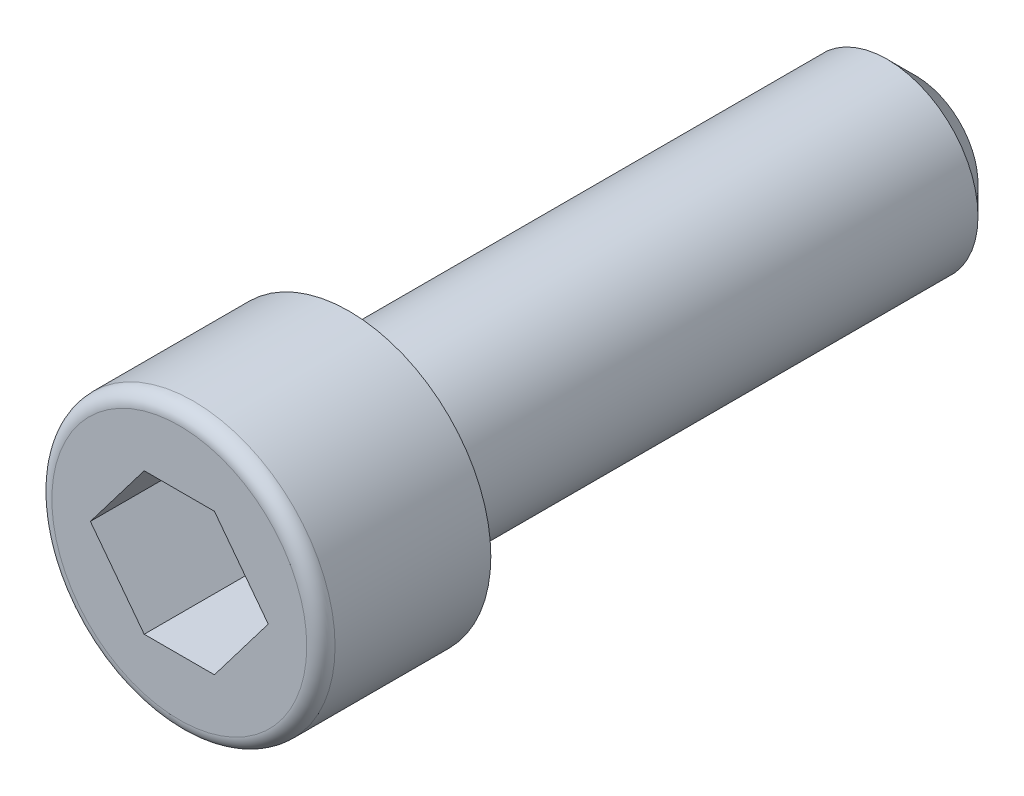
from build123d import *

# Parameters (mm, degrees)
ESQUISSE1_R             = 5
BASE_EXTRUSION_DEPTH    = 6
ESQUISSE2_R             = 3.201580403
BOSS_EXTRU_1_DEPTH      = 20
ENL_V_MAT_EXTRU_1_DEPTH = 5
CONG_1_R                = 0.5
CHANFREIN1_SIZE         = 1


with BuildPart() as part:
    # Esquisse1 → Base-Extrusion (new body)
    with BuildSketch(Plane.XY):
        Circle(ESQUISSE1_R)
    extrude(amount=BASE_EXTRUSION_DEPTH)

    # Esquisse2 → Boss.-Extru.1 (add)
    with BuildSketch(Plane(origin=(0, 0, 0), x_dir=(-1, 0, 0), z_dir=(0, 0, -1))):
        Circle(ESQUISSE2_R)
    extrude(amount=BOSS_EXTRU_1_DEPTH)

    # Esquisse3 → Enlèv. mat.-Extru.1 (cut)
    with BuildSketch(Plane.XY.offset(6)):
        Polygon((3.140063694, 0), (1.240063694, 2.5), (-1.240063694, 2.5), (-3.140063694, 0), (-1.240063694, -2.5), (1.240063694, -2.5), align=None)
    extrude(amount=-ENL_V_MAT_EXTRU_1_DEPTH, mode=Mode.SUBTRACT)

    # Congé1
    cong_1_edges = [part.edges().sort_by_distance(p)[0] for p in [
        (-5, 0, 6),
    ]]
    fillet(cong_1_edges, radius=CONG_1_R)

    # Chanfrein1
    chanfrein1_edges = [part.edges().sort_by_distance(p)[0] for p in [
        (3.201580403, 0, -20),
    ]]
    chamfer(chanfrein1_edges, length=CHANFREIN1_SIZE)


solid = part.part
